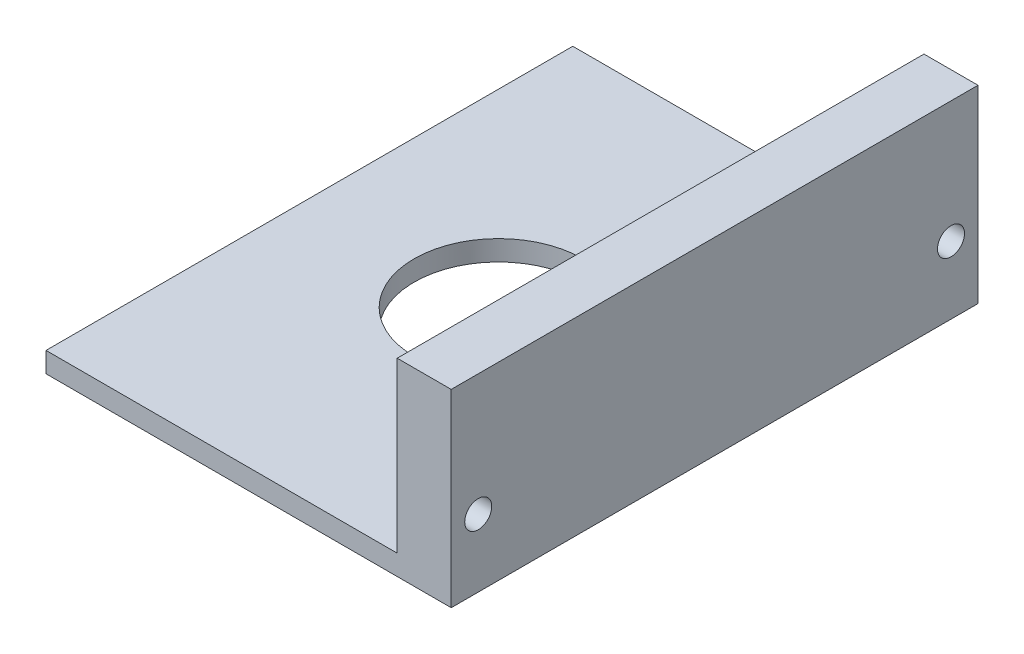
from build123d import *

# Parameters (mm, degrees)
SKETCH1_W           = 60
SKETCH1_H           = 78
BOSS_EXTRUDE1_DEPTH = 3
SKETCH2_W           = 8
SKETCH2_H           = 78
BOSS_EXTRUDE2_DEPTH = 25
SKETCH5_R           = 2
CUT_EXTRUDE2_DEPTH  = 30
SKETCH6_R           = 12.5
CUT_EXTRUDE3_DEPTH  = 29


with BuildPart() as part:
    # Sketch1 → Boss-Extrude1 (new body)
    with BuildSketch(Plane(origin=(0, 0, 0), x_dir=(1, 0, 0), z_dir=(0, 1, 0))):
        Rectangle(SKETCH1_W, SKETCH1_H)
    extrude(amount=BOSS_EXTRUDE1_DEPTH)

    # Sketch2 → Boss-Extrude2 (add)
    with BuildSketch(Plane(origin=(0, 3, 0), x_dir=(1, 0, 0), z_dir=(0, 1, 0))):
        with Locations((26, 0)):
            Rectangle(SKETCH2_W, SKETCH2_H)
    extrude(amount=BOSS_EXTRUDE2_DEPTH)

    # Sketch5 → Cut-Extrude2 (cut)
    with BuildSketch(Plane.ZY.offset(-22)):
        with Locations((35, 10)):
            Circle(SKETCH5_R)
        with Locations((-35, 10)):
            Circle(SKETCH5_R)
    extrude(amount=-CUT_EXTRUDE2_DEPTH, mode=Mode.SUBTRACT)

    # Sketch6 → Cut-Extrude3 (cut, through all)
    with BuildSketch(Plane(origin=(0, 0, 0), x_dir=(-1, 0, 0), z_dir=(0, -1, 0))):
        with Locations((2, 0)):
            Circle(SKETCH6_R)
    extrude(amount=-CUT_EXTRUDE3_DEPTH, mode=Mode.SUBTRACT)


solid = part.part
